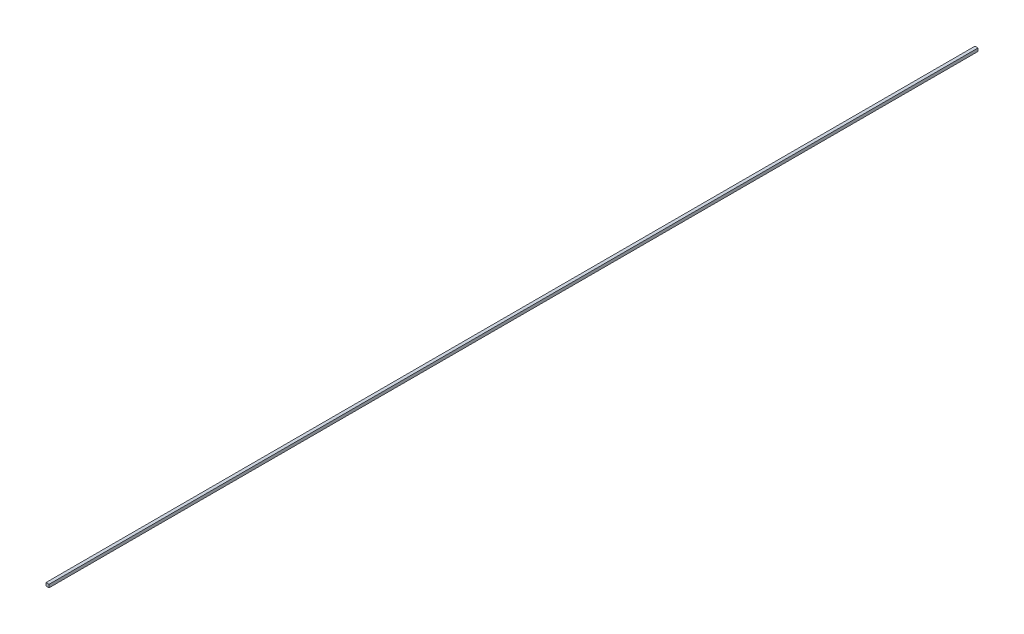
from build123d import *

# Parameters (mm, degrees)
SKETCH_1_W      = 2
SKETCH_1_H      = 2
EXTRUDE_1_DEPTH = 604.67


with BuildPart() as part:
    # ｽｹｯﾁ1 → ﾎﾞｽ - 押し出し1 (new body)
    with BuildSketch(Plane.XY):
        Rectangle(SKETCH_1_W, SKETCH_1_H)
    extrude(amount=EXTRUDE_1_DEPTH)


solid = part.part
